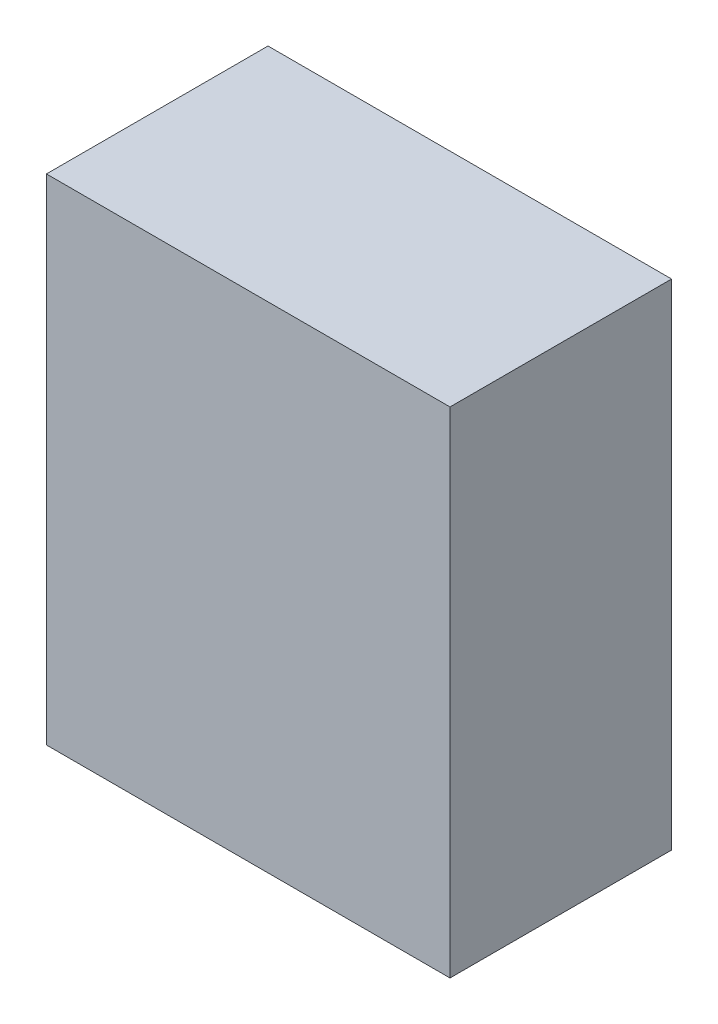
from build123d import *

# Parameters (mm, degrees)
SKETCH1_W           = 51
SKETCH1_H           = 62.5
BOSS_EXTRUDE1_DEPTH = 28


with BuildPart() as part:
    # Sketch1 → Boss-Extrude1 (new body)
    with BuildSketch(Plane.XY):
        Rectangle(SKETCH1_W, SKETCH1_H)
    extrude(amount=BOSS_EXTRUDE1_DEPTH)


solid = part.part
